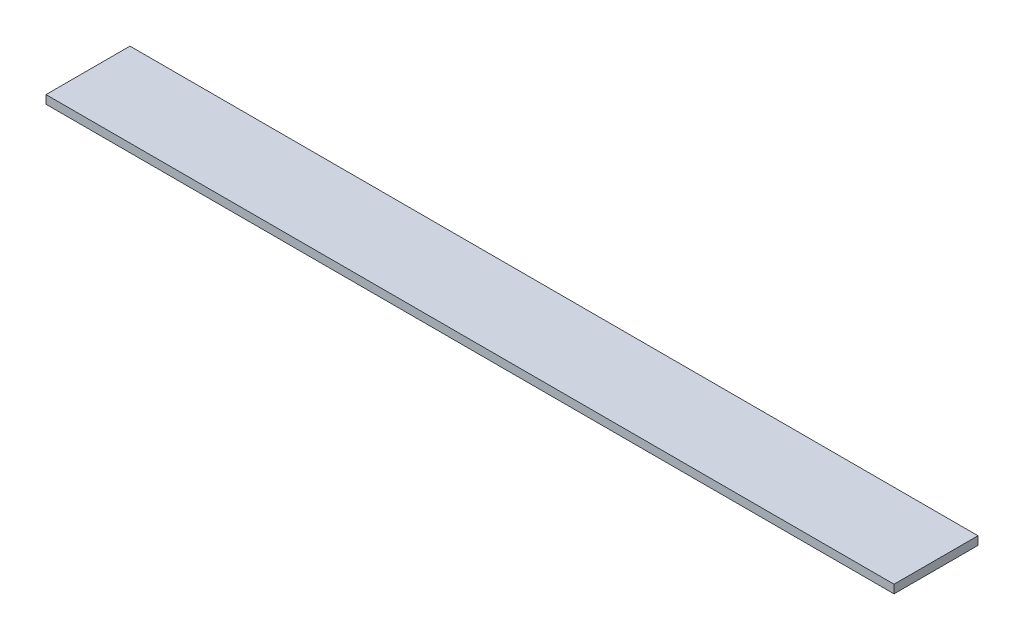
from build123d import *

# Parameters (mm, degrees)
SKETCH1_W           = 1010
SKETCH1_H           = 100
BOSS_EXTRUDE1_DEPTH = 10


with BuildPart() as part:
    # Sketch1 → Boss-Extrude1 (new body)
    with BuildSketch(Plane(origin=(0, 0, 0), x_dir=(1, 0, 0), z_dir=(0, 1, 0))):
        Rectangle(SKETCH1_W, SKETCH1_H)
    extrude(amount=BOSS_EXTRUDE1_DEPTH)


solid = part.part
